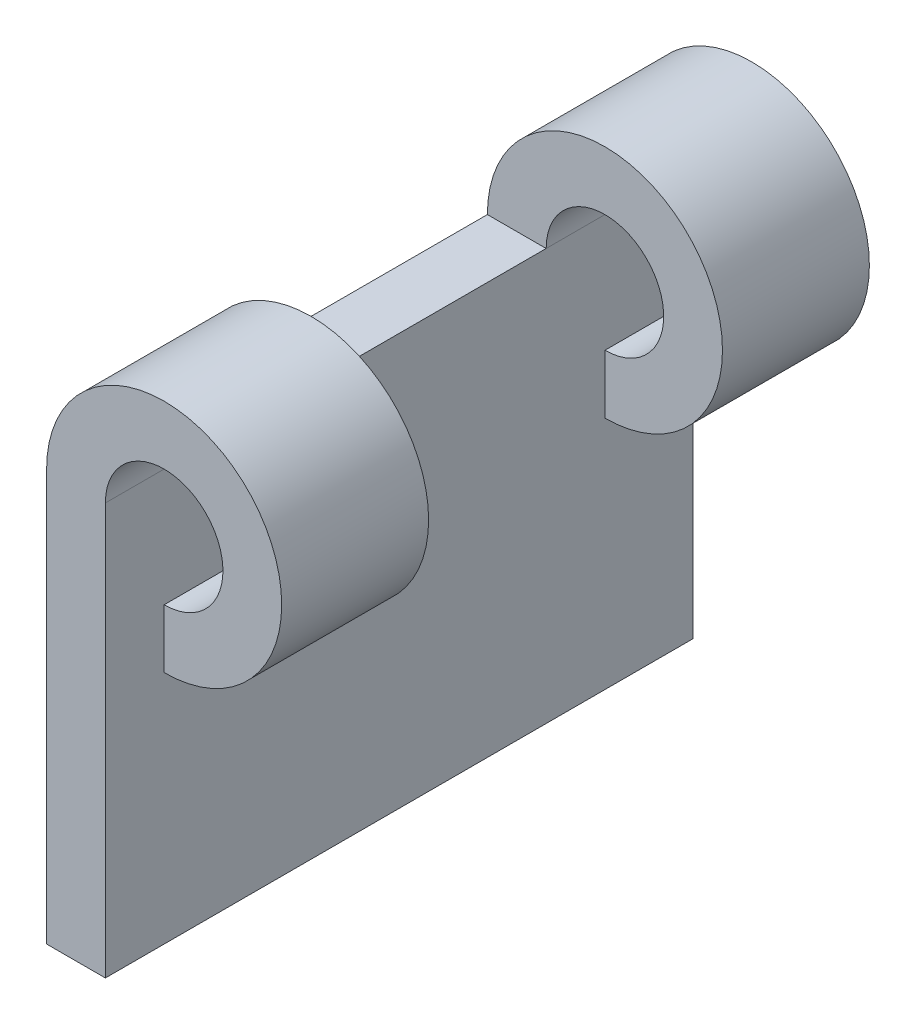
from build123d import *

# Parameters (mm, degrees)
BOSS_EXTRUDE1_DEPTH = 20
BOSS_EXTRUDE2_DEPTH = 5
BOSS_EXTRUDE3_START = 15
BOSS_EXTRUDE3_DEPTH = 5


with BuildPart() as part:
    # Sketch2 → Boss-Extrude1 (new body)
    with BuildSketch(Plane.XY):
        Polygon((0, 14), (0, 0), (2, 0), (2, 10.535898385), (2, 14), align=None)
    extrude(amount=BOSS_EXTRUDE1_DEPTH)

    # Sketch2_6 → Boss-Extrude3 (add)
    with BuildSketch(Plane.XY.offset(BOSS_EXTRUDE3_START)):
        with BuildLine():
            ThreePointArc((4, 10), (6.828427125, 16.828427125), (0, 14))
            Line((0, 14), (2, 14))
            ThreePointArc((2, 14), (4, 16), (6, 14))
            ThreePointArc((6, 14), (5.414213562, 12.585786438), (4, 12))
            Line((4, 12), (4, 10))
        make_face()
    extrude(amount=BOSS_EXTRUDE3_DEPTH)


with BuildPart() as body_2:
    # Sketch2_5 → Boss-Extrude2 (new body)
    with BuildSketch(Plane.XY):
        with BuildLine():
            ThreePointArc((4, 10), (6.828427125, 16.828427125), (0, 14))
            Line((0, 14), (2, 14))
            ThreePointArc((2, 14), (4, 16), (6, 14))
            ThreePointArc((6, 14), (5.414213562, 12.585786438), (4, 12))
            Line((4, 12), (4, 10))
        make_face()
    extrude(amount=BOSS_EXTRUDE2_DEPTH)


solid = Compound([part.part, body_2.part])
